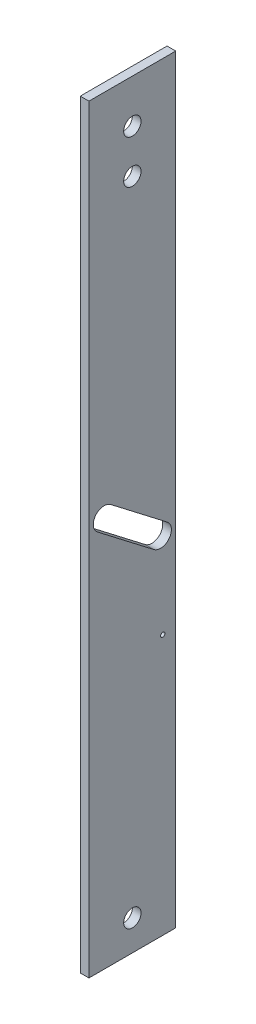
from build123d import *

# Parameters (mm, degrees)
SKETCH1_W           = 20
SKETCH1_H           = 175
BOSS_EXTRUDE1_DEPTH = 2
SKETCH2_R           = 2
SKETCH2_R_2         = 0.5
CUT_EXTRUDE1_DEPTH  = 2


with BuildPart() as part:
    # Sketch1 → Boss-Extrude1 (new body)
    with BuildSketch(Plane(origin=(0, 0, 0), x_dir=(0, 0, -1), z_dir=(1, 0, 0))):
        with Locations((10, 87.5)):
            Rectangle(SKETCH1_W, SKETCH1_H)
    extrude(amount=BOSS_EXTRUDE1_DEPTH)

    # Sketch2 → Cut-Extrude1 (cut)
    with BuildSketch(Plane(origin=(2, 0, 0), x_dir=(0, 0, -1), z_dir=(1, 0, 0))):
        with Locations((10, 7)):
            Circle(SKETCH2_R)
        with Locations((10, 165)):
            Circle(SKETCH2_R)
        with Locations((10, 155)):
            Circle(SKETCH2_R)
        with Locations((17, 60)):
            Circle(SKETCH2_R_2)
        with BuildLine():
            Line((14.975723098, 78.018440027), (1.975723098, 88.018440027))
            ThreePointArc((1.975723098, 88.018440027), (1.518440027, 91.524276902), (5.024276902, 91.981559973))
            Line((5.024276902, 91.981559973), (18.024276902, 81.981559973))
            ThreePointArc((18.024276902, 81.981559973), (18.481559973, 78.475723098), (14.975723098, 78.018440027))
        make_face()
    extrude(amount=-CUT_EXTRUDE1_DEPTH, mode=Mode.SUBTRACT)


solid = part.part
